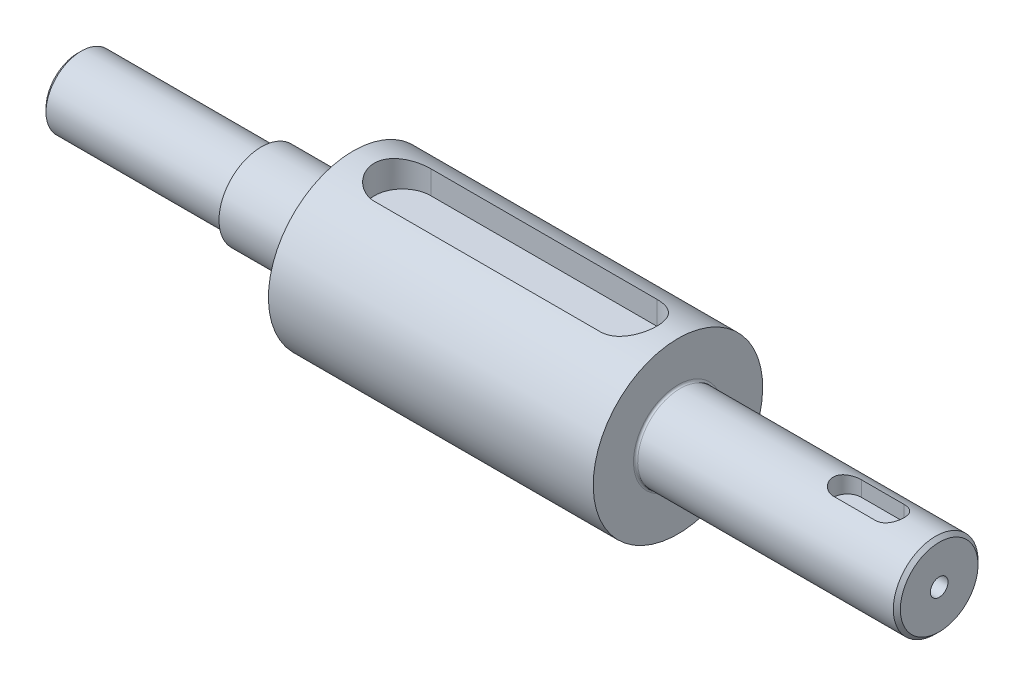
from build123d import *

# Parameters (mm, degrees)
CUT_EXTRUDE1_START              = 8
CUT_EXTRUDE1_DEPTH              = 4
SKETCH3_W                       = 8
SKETCH3_H                       = 5
CUT_EXTRUDE2_DEPTH              = 10
SKETCH4_R                       = 1.25
CUT_EXTRUDE3_DEPTH              = 4
SKETCH5_R                       = 6
CUT_EXTRUDE4_DEPTH              = 10
CUT_EXTRUDE5_START              = 6
CUT_EXTRUDE5_DEPTH              = 2.5
M3_TAPPED_HOLE1_D               = 2.5
M3_TAPPED_HOLE1_DEPTH           = 6.748924226
M3_TAPPED_HOLE1_TIP             = 0.751075774
M3_TAPPED_HOLE1_ON_FACE_2_D     = 2.5
M3_TAPPED_HOLE1_ON_FACE_2_DEPTH = 6.748924226
M3_TAPPED_HOLE1_ON_FACE_2_TIP   = 0.751075774
CHAMFER1_SIZE                   = 0.5
FILLET1_R                       = 0.3


with BuildPart() as part:
    # Sketch1 → Revolve1 (revolve)
    with BuildSketch(Plane.XY):
        Polygon((26, 6), (60, 6), (70, 6), (70, 0), (60, 0), (-60, 0), (-62, 0), (-62, 5), (-36, 5), (-36, 6), (-23, 6), (-23, 12), (23, 12), (23, 6), align=None)
    revolve(axis=Axis((60, 0, 0), (-1, 0, 0)))

    # Sketch2 → Cut-Extrude1 (cut)
    with BuildSketch(Plane(origin=(0, 0, 0), x_dir=(1, 0, 0), z_dir=(0, 1, 0)).offset(CUT_EXTRUDE1_START)):
        with BuildLine():
            Line((-16, 4), (16, 4))
            ThreePointArc((16, 4), (20, 0), (16, -4))
            Line((16, -4), (-16, -4))
            ThreePointArc((-16, -4), (-20, 0), (-16, 4))
        make_face()
    extrude(amount=CUT_EXTRUDE1_DEPTH, mode=Mode.SUBTRACT)

    # Sketch3 → Cut-Extrude2 (cut)
    with BuildSketch(Plane(origin=(70, 0, 0), x_dir=(0, 0, -1), z_dir=(1, 0, 0))):
        with Locations((0, 7)):
            Rectangle(SKETCH3_W, SKETCH3_H)
    extrude(amount=-CUT_EXTRUDE2_DEPTH, mode=Mode.SUBTRACT)

    # Sketch4 → Cut-Extrude3 (cut)
    with BuildSketch(Plane(origin=(0, 4.5, 0), x_dir=(1, 0, 0), z_dir=(0, 1, 0))):
        with Locations((65, 0)):
            Circle(SKETCH4_R)
    extrude(amount=-CUT_EXTRUDE3_DEPTH, mode=Mode.SUBTRACT)

    # Sketch5 → Cut-Extrude4 (cut)
    with BuildSketch(Plane(origin=(60, 0, 0), x_dir=(0, 0, -1), z_dir=(1, 0, 0))):
        Circle(SKETCH5_R)
    extrude(amount=CUT_EXTRUDE4_DEPTH, mode=Mode.SUBTRACT)

    # Sketch7 → Cut-Extrude5 (cut)
    with BuildSketch(Plane(origin=(0, 0, 0), x_dir=(1, 0, 0), z_dir=(0, 1, 0)).offset(CUT_EXTRUDE5_START)):
        with BuildLine():
            Line((47, 2), (53, 2))
            ThreePointArc((53, 2), (55, 0), (53, -2))
            Line((53, -2), (47, -2))
            ThreePointArc((47, -2), (45, 0), (47, 2))
        make_face()
    extrude(amount=-CUT_EXTRUDE5_DEPTH, mode=Mode.SUBTRACT)

    # M3 Tapped Hole1
    with Locations(Plane(origin=(-62, 0, 0), x_dir=(0, -1, 0), z_dir=(-1, 0, 0))):
        with Locations((0, 0)):
            Hole(M3_TAPPED_HOLE1_D / 2, depth=M3_TAPPED_HOLE1_DEPTH)
            with Locations((0, 0, -(M3_TAPPED_HOLE1_DEPTH + M3_TAPPED_HOLE1_TIP / 2))):  # 118° drill point
                Cone(0, M3_TAPPED_HOLE1_D / 2, M3_TAPPED_HOLE1_TIP, mode=Mode.SUBTRACT)

    # M3 Tapped Hole1 on face 2
    with Locations(Plane(origin=(60, 0, 0), x_dir=(0, 0, 1), z_dir=(1, 0, 0))):
        with Locations((0, 0)):
            Hole(M3_TAPPED_HOLE1_ON_FACE_2_D / 2, depth=M3_TAPPED_HOLE1_ON_FACE_2_DEPTH)
            with Locations((0, 0, -(M3_TAPPED_HOLE1_ON_FACE_2_DEPTH + M3_TAPPED_HOLE1_ON_FACE_2_TIP / 2))):  # 118° drill point
                Cone(0, M3_TAPPED_HOLE1_ON_FACE_2_D / 2, M3_TAPPED_HOLE1_ON_FACE_2_TIP, mode=Mode.SUBTRACT)

    # Chamfer1
    chamfer1_edges = [part.edges().sort_by_distance(p)[0] for p in [
        (-62, -5, 0),
        (60, -6, 0),
    ]]
    chamfer(chamfer1_edges, length=CHAMFER1_SIZE)

    # Fillet1
    fillet1_edges = [part.edges().sort_by_distance(p)[0] for p in [
        (-36, -5, 0),
        (-23, -6, 0),
        (23, -6, 0),
    ]]
    fillet(fillet1_edges, radius=FILLET1_R)


solid = part.part
